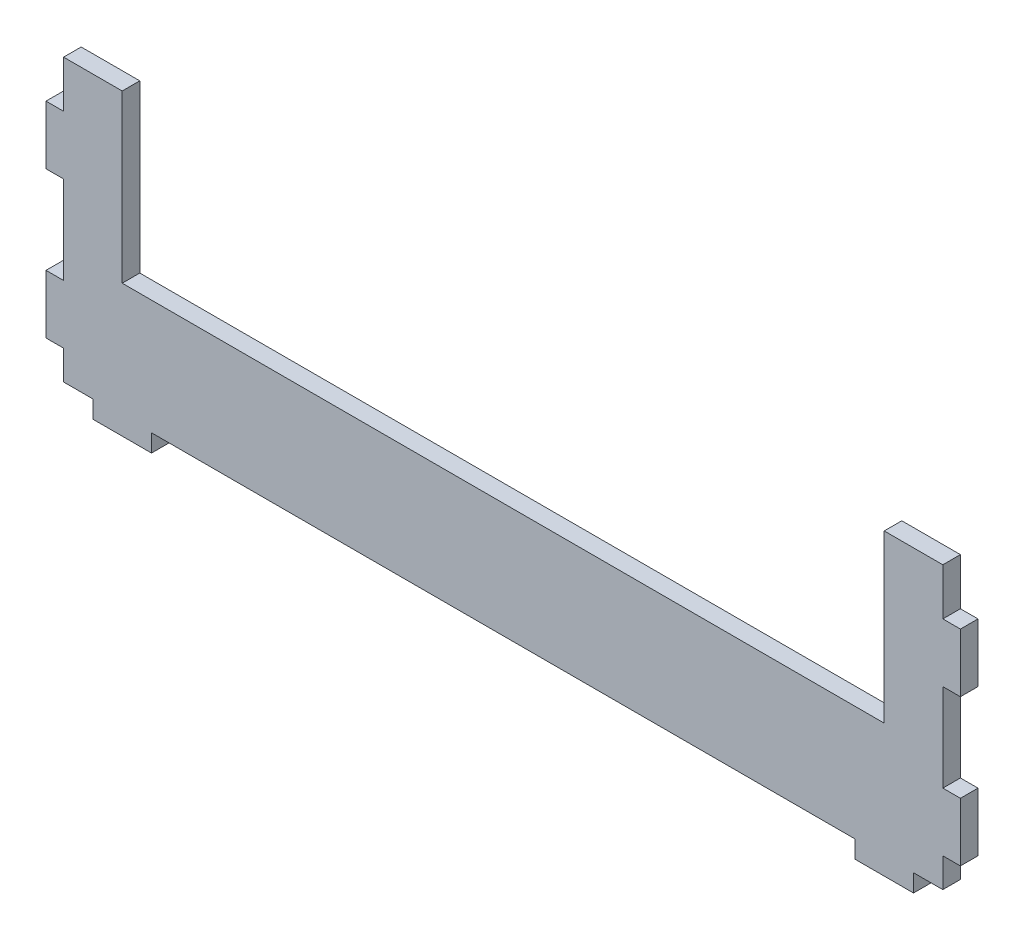
from build123d import *

# Parameters (mm, degrees)
BOSS_EXTRUDE1_DEPTH = 6


with BuildPart() as part:
    # Sketch1 → Boss-Extrude1 (new body)
    with BuildSketch(Plane.XY):
        Polygon((-495.568859933, 6), (-485.568859933, 6), (-485.568859933, 0), (-465.568859933, 0), (-465.568859933, 6), (-225.568859933, 6), (-225.568859933, 0), (-205.568859933, 0), (-205.568859933, 6), (-195.568859933, 6), (-195.568859933, 16), (-189.568859933, 16), (-189.568859933, 36), (-195.568859933, 36), (-195.568859933, 66), (-189.568859933, 66), (-189.568859933, 86), (-195.568859933, 86), (-195.568859933, 102), (-215.568859933, 102), (-215.568859933, 45.2), (-475.568859933, 45.2), (-475.568859933, 102), (-495.568859933, 102), (-495.568859933, 85.999999998), (-501.568859933, 85.999999998), (-501.568859933, 65.999999998), (-495.568859933, 65.999999998), (-495.568859933, 35.999999998), (-501.568859933, 35.999999998), (-501.568859933, 15.999999998), (-495.568859933, 15.999999998), align=None)
    extrude(amount=BOSS_EXTRUDE1_DEPTH)


solid = part.part
